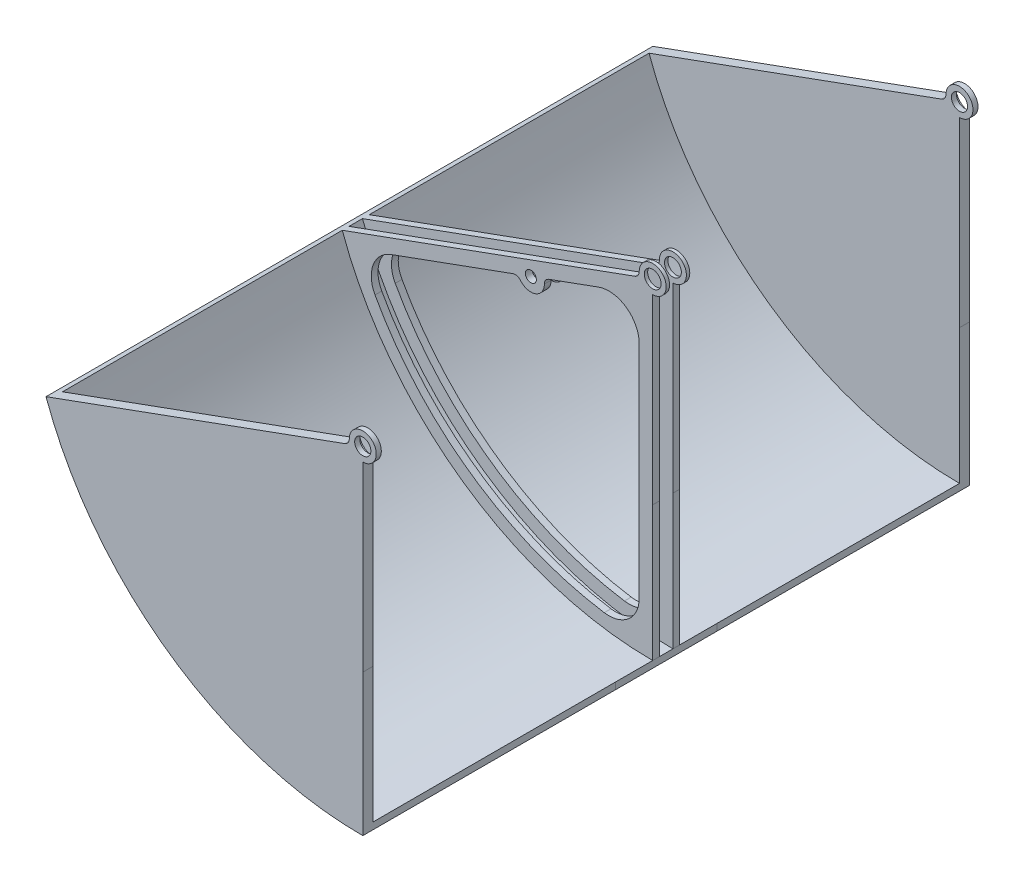
from build123d import *

# Parameters (mm, degrees)
DODANIE_WYCI_GNI_CIE1_DEPTH = 900
SKORUPA1_T                  = -10
SZKIC4_R                    = 12
DODANIE_WYCI_GNI_CIE3_DEPTH = 15
SZKIC6_R                    = 12.5
SZKIC6_R_2                  = 8.15
DODANIE_WYCI_GNI_CIE4_DEPTH = 10
ZAOKR_GLENIE3_R             = 45
SZKIC8_R                    = 20
WYTNIJ_WYCI_GNI_CIE1_DEPTH  = 7.5
SZKIC11_R                   = 20
WYTNIJ_WYCI_GNI_CIE2_DEPTH  = 5
SZKIC12_R                   = 20
WYTNIJ_WYCI_GNI_CIE3_DEPTH  = 5
SZKIC13_R                   = 20
WYTNIJ_WYCI_GNI_CIE4_DEPTH  = 7.5
ZAOKR_GLENIE4_R             = 10
ZAOKR_GLENIE5_R             = 10


with BuildPart() as part:
    # Szkic1 → Dodanie-wyciągnięcie1 (new body)
    with BuildSketch(Plane.XY):
        with BuildLine():
            Line((-469.846310393, -171.010071663), (0, 0))
            Line((0, 0), (0, -500))
            ThreePointArc((0, -500), (-286.788218176, -409.576022144), (-469.846310393, -171.010071663))
        make_face()
    extrude(amount=DODANIE_WYCI_GNI_CIE1_DEPTH)

    # Skorupa1
    skorupa1_openings = [part.faces().sort_by_distance(p)[0] for p in [
        (-179.521279962, -256.382958146, 900),
        (-179.521279962, -256.382958146, 0),
        (-234.923155196, -85.505035831, 450),
        (0, -250, 450),
    ]]
    offset(amount=SKORUPA1_T, openings=skorupa1_openings, kind=Kind.INTERSECTION)

    # Szkic4 → Dodanie-wyciągnięcie3 (add)
    with BuildSketch(Plane(origin=(0, 0, 0), x_dir=(-1, 0, 0), z_dir=(0, 0, -1))):
        with BuildLine():
            Line((0, -20), (0, -490))
            ThreePointArc((0, -490), (281.052453812, -401.384501702), (460.449384185, -167.58987023))
            Line((460.449384185, -167.58987023), (18.793852416, -6.840402867))
            ThreePointArc((18.793852416, -6.840402867), (-11.471528727, 16.383040886), (0, -20))
        make_face()
        Circle(SZKIC4_R, mode=Mode.SUBTRACT)
    dodanie_wyci_gni_cie3 = extrude(amount=-DODANIE_WYCI_GNI_CIE3_DEPTH)

    # Lustro1: Dodanie-wyciągnięcie3 across plane
    add(dodanie_wyci_gni_cie3.mirror(Plane.XY.offset(450)))

    # Szkic6 → Dodanie-wyciągnięcie4 (add)
    with BuildSketch(Plane.XY.offset(440)):
        with BuildLine():
            Line((-18.793852416, -6.840402867), (-460.449384185, -167.58987023))
            ThreePointArc((-460.449384185, -167.58987023), (-281.052453812, -401.384501702), (0, -490))
            Line((0, -490), (0, -20))
            ThreePointArc((0, -20), (11.471528727, 16.383040886), (-18.793852416, -6.840402867))
        make_face()
        Circle(SZKIC6_R, mode=Mode.SUBTRACT)
        with Locations((-180.698070908, -87.052274649)):
            Circle(SZKIC6_R_2, mode=Mode.SUBTRACT)
        with BuildLine():
            Line((-20, -28.562960135), (-20, -469.574275275))
            ThreePointArc((-20, -469.574275275), (-269.580925085, -385.001460816), (-434.41507852, -179.397713347))
            Line((-434.41507852, -179.397713347), (-199.491923324, -93.892677516))
            ThreePointArc((-199.491923324, -93.892677516), (-173.857668042, -105.846127065), (-161.904218492, -80.211871783))
            Line((-161.904218492, -80.211871783), (-20, -28.562960135))
        make_face(mode=Mode.SUBTRACT)
    dodanie_wyci_gni_cie4 = extrude(amount=-DODANIE_WYCI_GNI_CIE4_DEPTH)

    # Lustro6: Dodanie-wyciągnięcie4 across plane
    add(dodanie_wyci_gni_cie4.mirror(Plane.XY.offset(450)))

    # Zaokrąglenie3
    zaokr_glenie3_edges = [part.edges().sort_by_distance(p)[0] for p in [
        (-434.41507852, -179.397713347, 435),
        (-20, -28.562960135, 435),
        (-20, -469.574275275, 435),
        (-20, -469.574275275, 465),
        (-20, -28.562960135, 465),
        (-434.41507852, -179.397713347, 465),
    ]]
    fillet(zaokr_glenie3_edges, radius=ZAOKR_GLENIE3_R)

    # Szkic8 → Wytnij-wyciągnięcie1 (cut)
    with BuildSketch(Plane(origin=(0, 0, 0), x_dir=(-1, 0, 0), z_dir=(0, 0, -1))):
        Circle(SZKIC8_R)
    extrude(amount=-WYTNIJ_WYCI_GNI_CIE1_DEPTH, mode=Mode.SUBTRACT)

    # Szkic11 → Wytnij-wyciągnięcie2 (cut)
    with BuildSketch(Plane(origin=(0, 0, 430), x_dir=(-1, 0, 0), z_dir=(0, 0, -1))):
        Circle(SZKIC11_R)
    extrude(amount=-WYTNIJ_WYCI_GNI_CIE2_DEPTH, mode=Mode.SUBTRACT)

    # Szkic12 → Wytnij-wyciągnięcie3 (cut)
    with BuildSketch(Plane(origin=(0, 0, 460), x_dir=(-1, 0, 0), z_dir=(0, 0, -1))):
        Circle(SZKIC12_R)
    extrude(amount=-WYTNIJ_WYCI_GNI_CIE3_DEPTH, mode=Mode.SUBTRACT)

    # Szkic13 → Wytnij-wyciągnięcie4 (cut)
    with BuildSketch(Plane(origin=(0, 0, 885), x_dir=(-1, 0, 0), z_dir=(0, 0, -1))):
        Circle(SZKIC13_R)
    extrude(amount=-WYTNIJ_WYCI_GNI_CIE4_DEPTH, mode=Mode.SUBTRACT)

    # Zaokrąglenie4
    zaokr_glenie4_edges = [part.edges().sort_by_distance(p)[0] for p in [
        (-18.793852416, -6.840402867, 437.5),
        (-18.793852416, -6.840402867, 896.25),
        (-18.793852416, -6.840402867, 11.25),
        (-18.793852416, -6.840402867, 467.5),
    ]]
    fillet(zaokr_glenie4_edges, radius=ZAOKR_GLENIE4_R)

    # Zaokrąglenie5
    zaokr_glenie5_edges = [part.edges().sort_by_distance(p)[0] for p in [
        (-199.491923324, -93.892677516, 435),
        (-161.904218492, -80.211871783, 435),
        (-161.904218492, -80.211871783, 465),
        (-199.491923324, -93.892677516, 465),
    ]]
    fillet(zaokr_glenie5_edges, radius=ZAOKR_GLENIE5_R)


solid = part.part
